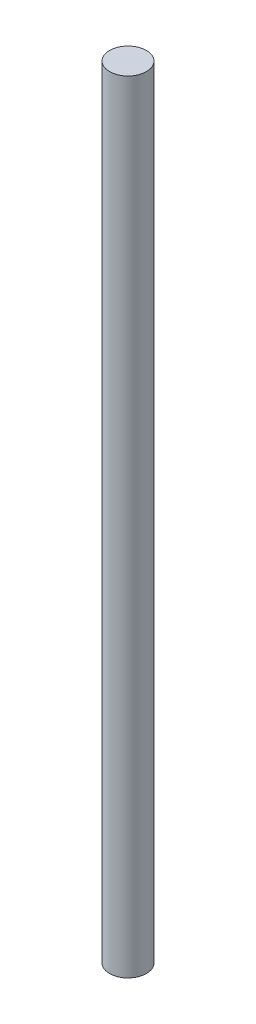
from build123d import *

# Parameters (mm, degrees)
SKETCH1_R           = 4
BOSS_EXTRUDE1_DEPTH = 169.962442034


with BuildPart() as part:
    # Sketch1 → Boss-Extrude1 (new body)
    with BuildSketch(Plane(origin=(0, 0, 0), x_dir=(1, 0, 0), z_dir=(0, 1, 0))):
        Circle(SKETCH1_R)
    extrude(amount=BOSS_EXTRUDE1_DEPTH)


solid = part.part
